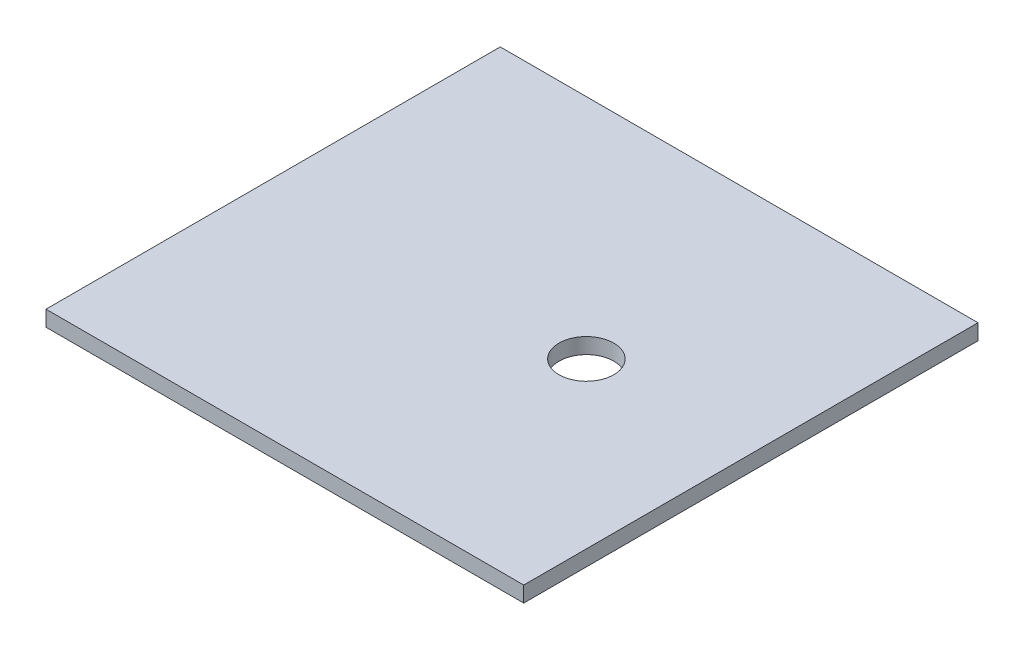
from build123d import *

# Parameters (mm, degrees)
SKETCH1_W           = 305
SKETCH1_H           = 290
SKETCH1_R           = 17.5
BOSS_EXTRUDE1_DEPTH = 10


with BuildPart() as part:
    # Sketch1 → Boss-Extrude1 (new body)
    with BuildSketch(Plane(origin=(0, 0, 0), x_dir=(1, 0, 0), z_dir=(0, 1, 0))):
        with Locations((-22.5, 0)):
            Rectangle(SKETCH1_W, SKETCH1_H)
        with Locations((25, 0)):
            Circle(SKETCH1_R, mode=Mode.SUBTRACT)
    extrude(amount=BOSS_EXTRUDE1_DEPTH)


solid = part.part
